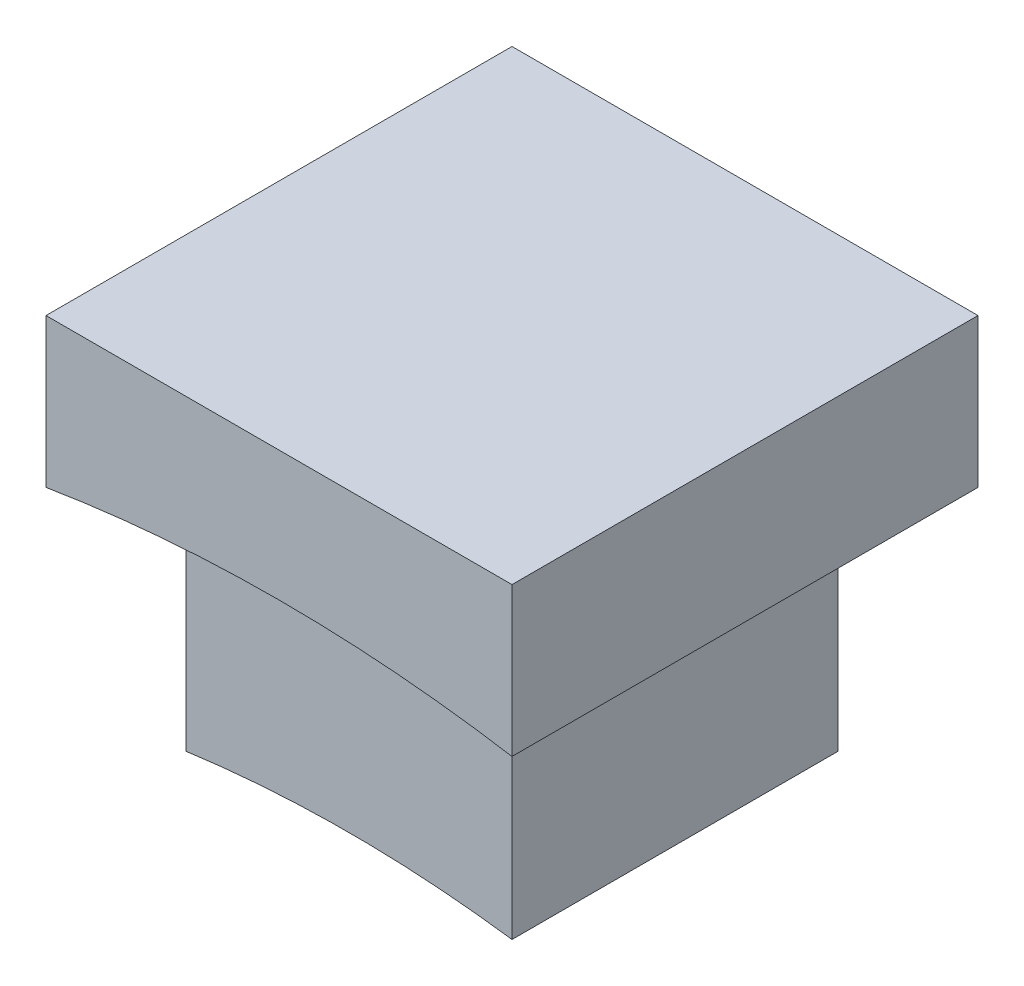
from build123d import *

# Parameters (mm, degrees)
SKETCH1_W               = 14
SKETCH1_H               = 14
BOSS_EXTRUDE1_DEPTH     = 10
SKETCH2_R               = 43.1
CUT_EXTRUDE1_DEPTH      = 8
CUT_EXTRUDE1_DEPTH_BACK = 8
SKETCH3_W               = 9.8
SKETCH3_H               = 9.8
BOSS_EXTRUDE2_DEPTH     = 15
SKETCH5_R               = 36
CUT_EXTRUDE2_DEPTH      = 8
CUT_EXTRUDE2_DEPTH_BACK = 8


with BuildPart() as part:
    # Sketch1 → Boss-Extrude1 (new body)
    with BuildSketch(Plane(origin=(0, 0, 0), x_dir=(1, 0, 0), z_dir=(0, 1, 0))):
        Rectangle(SKETCH1_W, SKETCH1_H)
    extrude(amount=BOSS_EXTRUDE1_DEPTH)

    # Sketch2 → Cut-Extrude1 (cut, two sides)
    with BuildSketch(Plane.XY) as cut_extrude1_sk:
        with Locations((0, -37)):
            Circle(SKETCH2_R)
    extrude(amount=CUT_EXTRUDE1_DEPTH, mode=Mode.SUBTRACT)
    extrude(cut_extrude1_sk.sketch, amount=-CUT_EXTRUDE1_DEPTH_BACK, mode=Mode.SUBTRACT)

    # Sketch3 → Boss-Extrude2 (add)
    with BuildSketch(Plane(origin=(0, 10, 0), x_dir=(1, 0, 0), z_dir=(0, 1, 0))):
        Rectangle(SKETCH3_W, SKETCH3_H)
    extrude(amount=-BOSS_EXTRUDE2_DEPTH)

    # Sketch5 → Cut-Extrude2 (cut, two sides)
    with BuildSketch(Plane.XY) as cut_extrude2_sk:
        with Locations((0, -37)):
            Circle(SKETCH5_R)
    extrude(amount=CUT_EXTRUDE2_DEPTH, mode=Mode.SUBTRACT)
    extrude(cut_extrude2_sk.sketch, amount=-CUT_EXTRUDE2_DEPTH_BACK, mode=Mode.SUBTRACT)


solid = part.part
